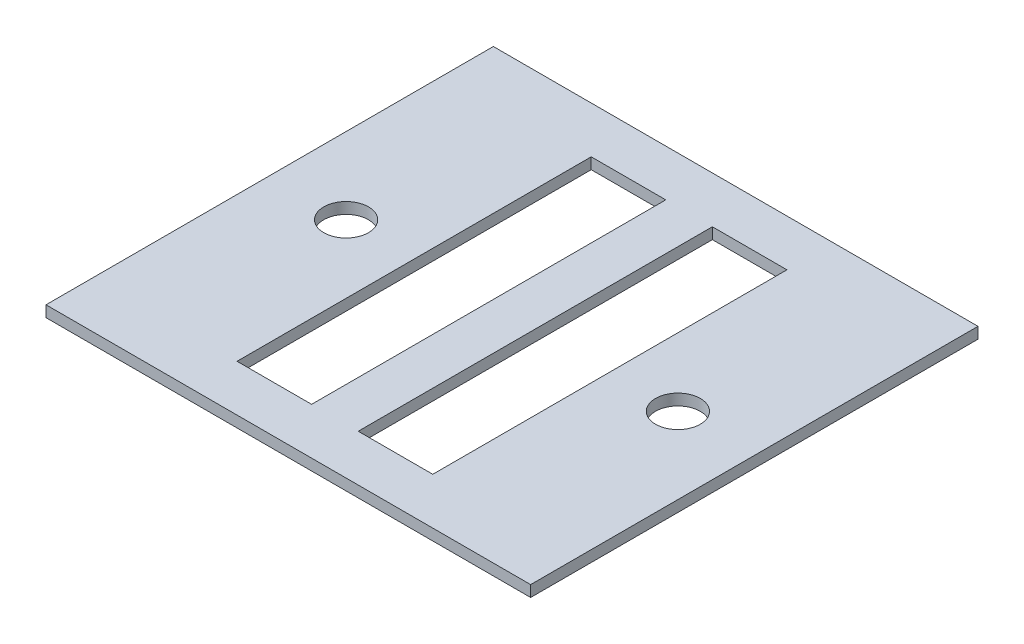
from build123d import *

# Parameters (mm, degrees)
SKETCH1_W           = 130
SKETCH1_H           = 120
BOSS_EXTRUDE1_DEPTH = 3
CUT_EXTRUDE1_START  = -4
SKETCH2_W           = 20
SKETCH2_H           = 95
CUT_EXTRUDE1_DEPTH  = 5
CUT_EXTRUDE2_START  = -4
SKETCH3_R           = 6
CUT_EXTRUDE2_DEPTH  = 5


with BuildPart() as part:
    # Sketch1 → Boss-Extrude1 (new body)
    with BuildSketch(Plane(origin=(0, 0, 0), x_dir=(1, 0, 0), z_dir=(0, 1, 0))):
        Rectangle(SKETCH1_W, SKETCH1_H)
    extrude(amount=BOSS_EXTRUDE1_DEPTH)

    # Sketch2 → Cut-Extrude1 (cut)
    with BuildSketch(Plane(origin=(0, 3, 0), x_dir=(1, 0, 0), z_dir=(0, 1, 0)).offset(CUT_EXTRUDE1_START)):
        with Locations((-16.25, 0)):
            Rectangle(SKETCH2_W, SKETCH2_H)
    cut_extrude1 = extrude(amount=CUT_EXTRUDE1_DEPTH, mode=Mode.SUBTRACT)

    # Mirror1: Cut-Extrude1 across plane
    add(cut_extrude1.mirror(Plane(origin=(0, 0, 0), x_dir=(0, 0, 1), z_dir=(1, 0, 0))), mode=Mode.SUBTRACT)

    # Sketch3 → Cut-Extrude2 (cut)
    with BuildSketch(Plane(origin=(0, 3, 0), x_dir=(1, 0, 0), z_dir=(0, 1, 0)).offset(CUT_EXTRUDE2_START)):
        with Locations((44.5, 0)):
            Circle(SKETCH3_R)
    cut_extrude2 = extrude(amount=CUT_EXTRUDE2_DEPTH, mode=Mode.SUBTRACT)

    # Mirror2: Cut-Extrude2 across plane
    add(cut_extrude2.mirror(Plane(origin=(0, 0, 0), x_dir=(0, 0, 1), z_dir=(1, 0, 0))), mode=Mode.SUBTRACT)


solid = part.part
